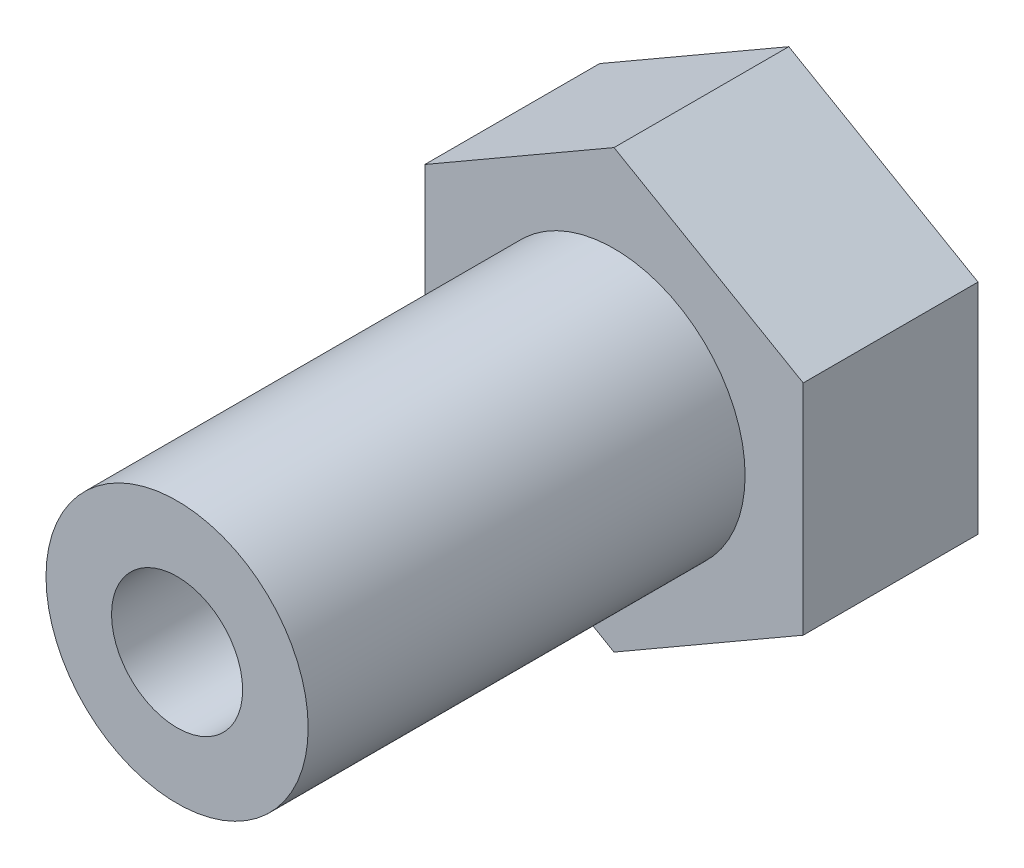
from build123d import *

# Parameters (mm, degrees)
ESBO_O1_R                = 3
RESSALTO_EXTRUS_O1_DEPTH = 8
ESBO_O2_R                = 5
ESBO_O2_R_2              = 3
RESSALTO_EXTRUS_O2_DEPTH = 1
ESBO_O3_R                = 6
ESBO_O3_R_2              = 3
RESSALTO_EXTRUS_O3_DEPTH = 20


with BuildPart() as part:
    # Esboço1 → Ressalto-extrusão1 (new body)
    with BuildSketch(Plane.XY):
        Polygon((-8.660254038, 5), (-8.660254038, -5), (0, -10), (8.660254038, -5), (8.660254038, 5), (0, 10), align=None)
        Circle(ESBO_O1_R, mode=Mode.SUBTRACT)
    extrude(amount=RESSALTO_EXTRUS_O1_DEPTH)

    # Esboço2 → Ressalto-extrusão2 (add)
    with BuildSketch(Plane(origin=(0, 0, 0), x_dir=(-1, 0, 0), z_dir=(0, 0, -1))):
        Circle(ESBO_O2_R)
        Circle(ESBO_O2_R_2, mode=Mode.SUBTRACT)
    extrude(amount=RESSALTO_EXTRUS_O2_DEPTH)

    # Esboço3 → Ressalto-extrusão3 (add)
    with BuildSketch(Plane.XY.offset(8)):
        Circle(ESBO_O3_R)
        Circle(ESBO_O3_R_2, mode=Mode.SUBTRACT)
    extrude(amount=RESSALTO_EXTRUS_O3_DEPTH)


solid = part.part
